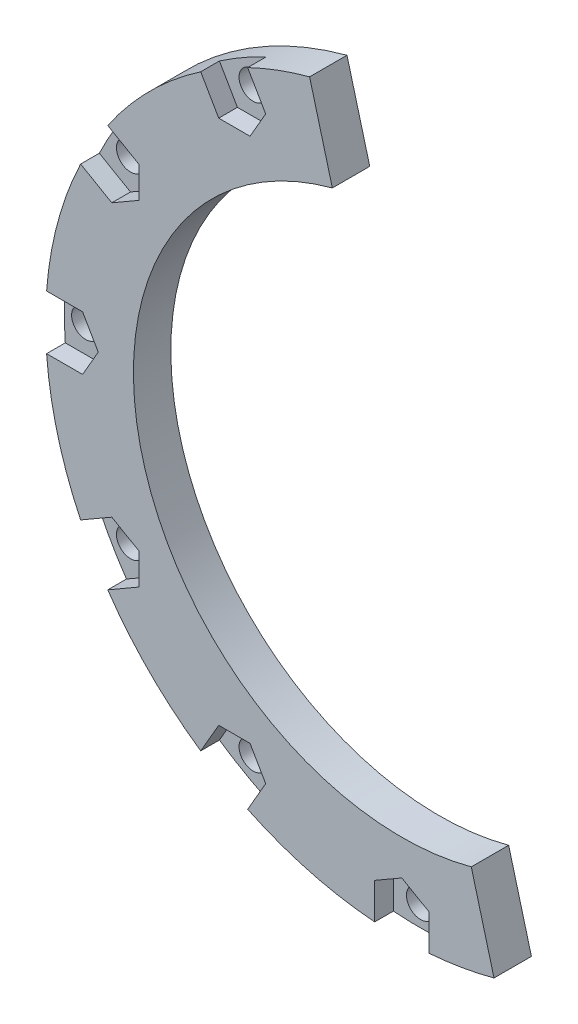
from build123d import *

# Parameters (mm, degrees)
SKETCH1_R               = 38.1
SKETCH1_R_2             = 28.702
BOSS_EXTRUDE1_DEPTH     = 4
SKETCH2_R               = 1.5
CUT_EXTRUDE1_DEPTH      = 5
CUT_EXTRUDE2_DEPTH      = 2
CUT_EXTRUDE3_DEPTH      = 1
CUT_EXTRUDE3_DEPTH_BACK = 5


with BuildPart() as part:
    # Sketch1 → Boss-Extrude1 (new body)
    with BuildSketch(Plane.XY):
        Circle(SKETCH1_R)
        Circle(SKETCH1_R_2, mode=Mode.SUBTRACT)
    extrude(amount=BOSS_EXTRUDE1_DEPTH)

    # Sketch2 → Cut-Extrude1 (cut, through all)
    with BuildSketch(Plane.XY.offset(4)):
        with Locations((0, 35.814)):
            Circle(SKETCH2_R)
        with Locations((17.907, 31.015833811)):
            Circle(SKETCH2_R)
        with Locations((31.015833811, 17.907)):
            Circle(SKETCH2_R)
        with Locations((35.814, 0)):
            Circle(SKETCH2_R)
        with Locations((31.015833811, -17.907)):
            Circle(SKETCH2_R)
        with Locations((17.907, -31.015833811)):
            Circle(SKETCH2_R)
        with Locations((0, -35.814)):
            Circle(SKETCH2_R)
        with Locations((-17.907, -31.015833811)):
            Circle(SKETCH2_R)
        with Locations((-31.015833811, -17.907)):
            Circle(SKETCH2_R)
        with Locations((-35.814, 0)):
            Circle(SKETCH2_R)
        with Locations((-31.015833811, 17.907)):
            Circle(SKETCH2_R)
        with Locations((-17.907, 31.015833811)):
            Circle(SKETCH2_R)
    extrude(amount=-CUT_EXTRUDE1_DEPTH, mode=Mode.SUBTRACT)

    # Sketch3 → Cut-Extrude2 (cut)
    with BuildSketch(Plane.XY.offset(4)):
        Polygon((-2.9, 37.989472226), (0, 39.162631561), (2.9, 37.989472226), (2.9, 34.139684219), (0, 32.465368439), (-2.9, 34.139684219), align=None)
        Polygon((16.483262442, 34.349848024), (19.581315781, 33.915833811), (21.506209784, 31.449848024), (19.581315781, 28.115833811), (16.232684219, 28.115833811), (14.558368439, 31.015833811), align=None)
        Polygon((31.449848024, 21.506209784), (33.915833811, 19.581315781), (34.349848024, 16.483262442), (31.015833811, 14.558368439), (28.115833811, 16.232684219), (28.115833811, 19.581315781), align=None)
        Polygon((37.989472226, 2.9), (39.162631561, 0), (37.989472226, -2.9), (34.139684219, -2.9), (32.465368439, 0), (34.139684219, 2.9), align=None)
        Polygon((34.349848024, -16.483262442), (33.915833811, -19.581315781), (31.449848024, -21.506209784), (28.115833811, -19.581315781), (28.115833811, -16.232684219), (31.015833811, -14.558368439), align=None)
        Polygon((21.506209784, -31.449848024), (19.581315781, -33.915833811), (16.483262442, -34.349848024), (14.558368439, -31.015833811), (16.232684219, -28.115833811), (19.581315781, -28.115833811), align=None)
        Polygon((2.9, -37.989472226), (0, -39.162631561), (-2.9, -37.989472226), (-2.9, -34.139684219), (0, -32.465368439), (2.9, -34.139684219), align=None)
        Polygon((-16.483262442, -34.349848024), (-19.581315781, -33.915833811), (-21.506209784, -31.449848024), (-19.581315781, -28.115833811), (-16.232684219, -28.115833811), (-14.558368439, -31.015833811), align=None)
        Polygon((-31.449848024, -21.506209784), (-33.915833811, -19.581315781), (-34.349848024, -16.483262442), (-31.015833811, -14.558368439), (-28.115833811, -16.232684219), (-28.115833811, -19.581315781), align=None)
        Polygon((-37.989472226, -2.9), (-39.162631561, 0), (-37.989472226, 2.9), (-34.139684219, 2.9), (-32.465368439, 0), (-34.139684219, -2.9), align=None)
        Polygon((-34.349848024, 16.483262442), (-33.915833811, 19.581315781), (-31.449848024, 21.506209784), (-28.115833811, 19.581315781), (-28.115833811, 16.232684219), (-31.015833811, 14.558368439), align=None)
        Polygon((-21.506209784, 31.449848024), (-19.581315781, 33.915833811), (-16.483262442, 34.349848024), (-14.558368439, 31.015833811), (-16.232684219, 28.115833811), (-19.581315781, 28.115833811), align=None)
    extrude(amount=-CUT_EXTRUDE2_DEPTH, mode=Mode.SUBTRACT)

    # Sketch4 → Cut-Extrude3 (cut, two sides)
    with BuildSketch(Plane.XY.offset(4)) as cut_extrude3_sk:
        with BuildLine():
            Line((-9.861005618, 36.801773982), (9.861005618, -36.801773982))
            ThreePointArc((9.861005618, -36.801773982), (36.801773982, 9.861005618), (-9.861005618, 36.801773982))
        make_face()
    extrude(amount=CUT_EXTRUDE3_DEPTH, mode=Mode.SUBTRACT)
    extrude(cut_extrude3_sk.sketch, amount=-CUT_EXTRUDE3_DEPTH_BACK, mode=Mode.SUBTRACT)


solid = part.part
